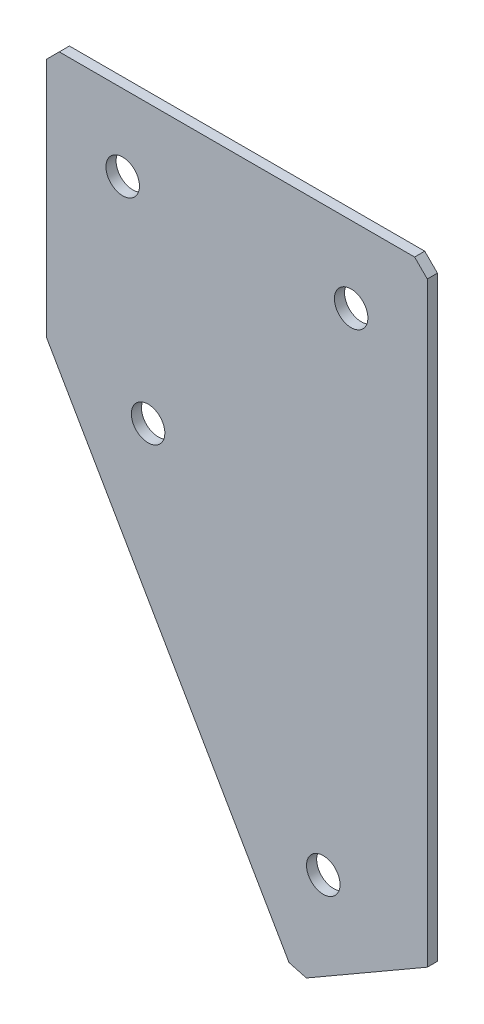
from build123d import *

# Parameters (mm, degrees)
EXTRUDE_1_DEPTH   = 2
HOLE_WIZARD_M61_D = 6.6
CHAMFER_1_SIZE    = 2.5


with BuildPart() as part:
    # Эскиз3 → Бобышка-Вытянуть1 (new body)
    with BuildSketch(Plane(origin=(0, 0, 0), x_dir=(1, 0, 0), z_dir=(0, 0, -1))):
        Polygon((0, 0), (75, 0), (75, 119.903810568), (49.019237886, 134.903810568), (0, 50), align=None)
    extrude(amount=EXTRUDE_1_DEPTH)

    # Отверстие с зазором M61 (through all)
    with Locations(Plane(origin=(0, 0, -2), x_dir=(1, 0, 0), z_dir=(0, 0, -1))):
        with Locations((15, 15), (60, 15), (20, 54.641016151), (54.509618943, 114.413429511)):
            Hole(HOLE_WIZARD_M61_D / 2)

    # Фаска1
    chamfer_1_edges = [part.edges().sort_by_distance(p)[0] for p in [
        (49.019237886, -134.903810568, -1),
        (75, 0, -1),
        (0, 0, -1),
    ]]
    chamfer(chamfer_1_edges, length=CHAMFER_1_SIZE)


solid = part.part
